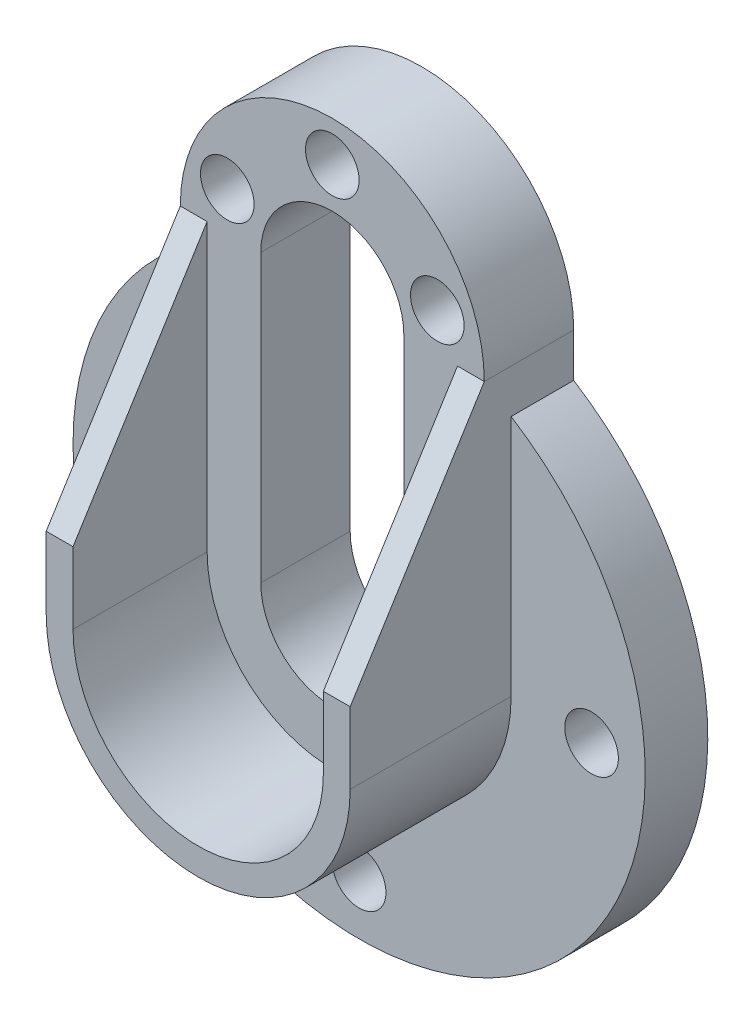
from build123d import *

# Parameters (mm, degrees)
SKETCH1_R           = 4.7625
BOSS_EXTRUDE1_DEPTH = 11.1125
SKETCH1_3_R         = 4.7625
BOSS_EXTRUDE2_DEPTH = 15.875
BOSS_EXTRUDE3_DEPTH = 39.6875
CUT_EXTRUDE1_DEPTH  = 117.948227728


with BuildPart() as part:
    # Sketch1 → Boss-Extrude1 (new body)
    with BuildSketch(Plane.XY):
        with BuildLine():
            Line((-26.9875, 50.8), (-26.9875, 43.038527435))
            ThreePointArc((-26.9875, 43.038527435), (0, -50.8), (26.9875, 43.038527435))
            Line((26.9875, 43.038527435), (26.9875, 50.8))
            ThreePointArc((26.9875, 50.8), (0, 77.7875), (-26.9875, 50.8))
        make_face()
        with Locations((0, -41.275)):
            Circle(SKETCH1_R, mode=Mode.SUBTRACT)
        with Locations((-41.275, 0)):
            Circle(SKETCH1_R, mode=Mode.SUBTRACT)
        with Locations((41.275, 0)):
            Circle(SKETCH1_R, mode=Mode.SUBTRACT)
        with BuildLine():
            Line((12.7, 50.8), (12.7, 0))
            ThreePointArc((12.7, 0), (0, -12.7), (-12.7, 0))
            Line((-12.7, 0), (-12.7, 50.8))
            ThreePointArc((-12.7, 50.8), (0, 63.5), (12.7, 50.8))
        make_face(mode=Mode.SUBTRACT)
        with Locations((-18.647025444, 57.586962219)):
            Circle(SKETCH1_R, mode=Mode.SUBTRACT)
        with Locations((0, 70.64375)):
            Circle(SKETCH1_R, mode=Mode.SUBTRACT)
        with Locations((18.647025444, 57.586962219)):
            Circle(SKETCH1_R, mode=Mode.SUBTRACT)
    extrude(amount=BOSS_EXTRUDE1_DEPTH)

    # Sketch1_3 → Boss-Extrude2 (add)
    with BuildSketch(Plane.XY):
        with BuildLine():
            ThreePointArc((-26.9875, 0), (0, -26.9875), (26.9875, 0))
            Line((26.9875, 0), (26.9875, 50.8))
            ThreePointArc((26.9875, 50.8), (0, 77.7875), (-26.9875, 50.8))
            Line((-26.9875, 50.8), (-26.9875, 0))
        make_face()
        with BuildLine():
            Line((12.7, 50.8), (12.7, 0))
            ThreePointArc((12.7, 0), (0, -12.7), (-12.7, 0))
            Line((-12.7, 0), (-12.7, 50.8))
            ThreePointArc((-12.7, 50.8), (0, 63.5), (12.7, 50.8))
        make_face(mode=Mode.SUBTRACT)
        with Locations((-18.647025444, 57.586962219)):
            Circle(SKETCH1_3_R, mode=Mode.SUBTRACT)
        with Locations((0, 70.64375)):
            Circle(SKETCH1_3_R, mode=Mode.SUBTRACT)
        with Locations((18.647025444, 57.586962219)):
            Circle(SKETCH1_3_R, mode=Mode.SUBTRACT)
    extrude(amount=BOSS_EXTRUDE2_DEPTH)

    # Sketch1_4 → Boss-Extrude3 (add)
    with BuildSketch(Plane.XY):
        with BuildLine():
            ThreePointArc((-26.9875, 0), (0, -26.9875), (26.9875, 0))
            Line((26.9875, 0), (26.9875, 43.038527435))
            Line((26.9875, 43.038527435), (26.9875, 50.8))
            Line((26.9875, 50.8), (22.225, 50.8))
            Line((22.225, 50.8), (22.225, 0))
            ThreePointArc((22.225, 0), (0, -22.225), (-22.225, 0))
            Line((-22.225, 0), (-22.225, 50.8))
            Line((-22.225, 50.8), (-26.9875, 50.8))
            Line((-26.9875, 50.8), (-26.9875, 43.038527435))
            Line((-26.9875, 43.038527435), (-26.9875, 0))
        make_face()
    extrude(amount=BOSS_EXTRUDE3_DEPTH)

    # Sketch2 → Cut-Extrude1 (cut, through all)
    with BuildSketch(Plane(origin=(26.9875, 0, 0), x_dir=(0, 0, -1), z_dir=(1, 0, 0))):
        Polygon((-15.875, 50.8), (-39.6875, 12.7), (-39.6875, 50.8), align=None)
    extrude(amount=-CUT_EXTRUDE1_DEPTH, mode=Mode.SUBTRACT)


solid = part.part
